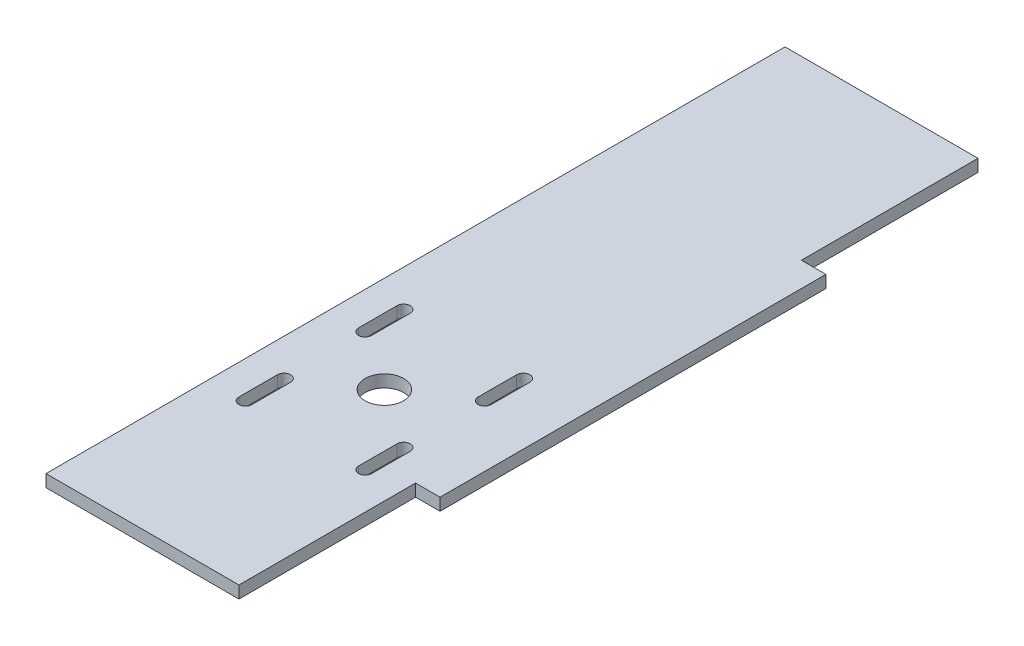
from build123d import *

# Parameters (mm, degrees)
BOSS_EXTRUDE1_DEPTH  = 3.175
SKETCH3_R            = 5
CUT_EXTRUDE1_DEPTH   = 150.117288149
M3_CLEARANCE_HOLE1_D = 3.4
CUT_EXTRUDE2_DEPTH   = 150.117288149


with BuildPart() as part:
    # Sketch1 → Boss-Extrude1 (new body)
    with BuildSketch(Plane(origin=(0, 0, 0), x_dir=(1, 0, 0), z_dir=(0, 1, 0))):
        Polygon((-25, 0), (-25, 45.75), (25, 45.75), (25, 0), (31.35, 0), (31.35, -100), (25, -100), (25, -145.75), (-25, -145.75), (-25, -100), align=None)
    extrude(amount=BOSS_EXTRUDE1_DEPTH)

    # Sketch3 → Cut-Extrude1 (cut, through all)
    with BuildSketch(Plane(origin=(0, 3.175, 0), x_dir=(1, 0, 0), z_dir=(0, 1, 0))):
        with Locations(Location((0, -83.075, 0), (0, 0, 270))):
            Circle(SKETCH3_R)
    extrude(amount=-CUT_EXTRUDE1_DEPTH, mode=Mode.SUBTRACT)

    # M3 Clearance Hole1 (through all)
    with Locations(Plane(origin=(0, 3.175, 0), x_dir=(1, 0, 0), z_dir=(0, 1, 0))):
        with Locations((15.5, -98.575), (-15.5, -98.575), (-15.5, -67.575), (15.5, -67.575)):
            Hole(M3_CLEARANCE_HOLE1_D / 2)

    # Sketch6 → Cut-Extrude2 (cut, through all)
    with BuildSketch(Plane.XZ):
        with BuildLine():
            Line((17.2, 103.575), (17.2, 93.575))
            ThreePointArc((17.2, 93.575), (15.5, 91.875), (13.8, 93.575))
            Line((13.8, 93.575), (13.8, 103.575))
            ThreePointArc((13.8, 103.575), (15.5, 105.275), (17.2, 103.575))
        make_face()
        with BuildLine():
            Line((-13.8, 103.575), (-13.8, 93.575))
            ThreePointArc((-13.8, 93.575), (-15.5, 91.875), (-17.2, 93.575))
            Line((-17.2, 93.575), (-17.2, 103.575))
            ThreePointArc((-17.2, 103.575), (-15.5, 105.275), (-13.8, 103.575))
        make_face()
        with BuildLine():
            Line((17.2, 62.575), (17.2, 72.575))
            ThreePointArc((17.2, 72.575), (15.5, 74.275), (13.8, 72.575))
            Line((13.8, 72.575), (13.8, 62.575))
            ThreePointArc((13.8, 62.575), (15.5, 60.875), (17.2, 62.575))
        make_face()
        with BuildLine():
            Line((-13.8, 62.575), (-13.8, 72.575))
            ThreePointArc((-13.8, 72.575), (-15.5, 74.275), (-17.2, 72.575))
            Line((-17.2, 72.575), (-17.2, 62.575))
            ThreePointArc((-17.2, 62.575), (-15.5, 60.875), (-13.8, 62.575))
        make_face()
    extrude(amount=-CUT_EXTRUDE2_DEPTH, mode=Mode.SUBTRACT)


solid = part.part
